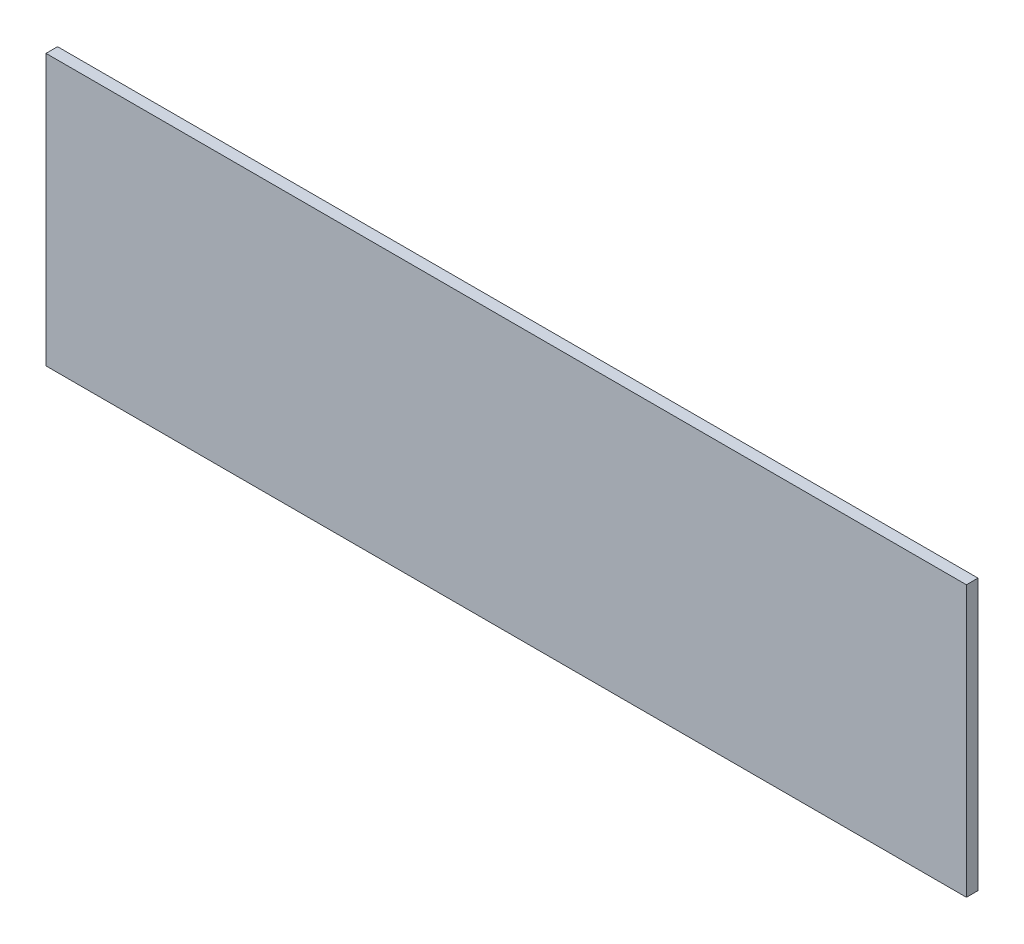
from build123d import *

# Parameters (mm, degrees)
SKETCH1_W           = 946.658829024
SKETCH1_H           = 278.403201521
BOSS_EXTRUDE1_DEPTH = 11.90625


with BuildPart() as part:
    # Sketch1 → Boss-Extrude1 (new body)
    with BuildSketch(Plane.XY):
        with Locations((0, -547.836354616)):
            Rectangle(SKETCH1_W, SKETCH1_H)
    extrude(amount=-BOSS_EXTRUDE1_DEPTH)


solid = part.part
